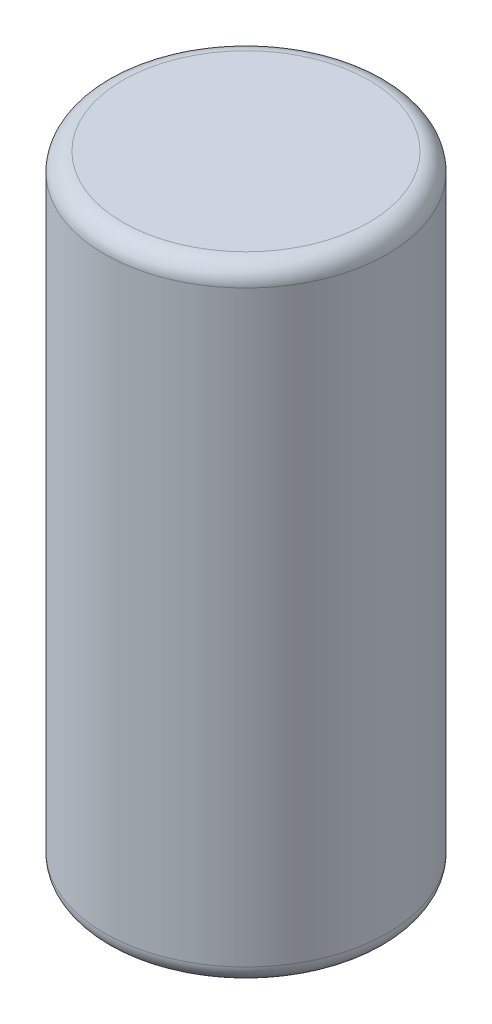
from build123d import *

# Parameters (mm, degrees)
SKETCH1_R           = 77
BOSS_EXTRUDE1_DEPTH = 340
FILLET1_R           = 10


with BuildPart() as part:
    # Sketch1 → Boss-Extrude1 (new body)
    with BuildSketch(Plane(origin=(0, 0, 0), x_dir=(1, 0, 0), z_dir=(0, 1, 0))):
        Circle(SKETCH1_R)
    extrude(amount=BOSS_EXTRUDE1_DEPTH)

    # Fillet1
    fillet1_edges = [part.edges().sort_by_distance(p)[0] for p in [
        (-77, 0, 0),
        (-77, 340, 0),
    ]]
    fillet(fillet1_edges, radius=FILLET1_R)


solid = part.part
